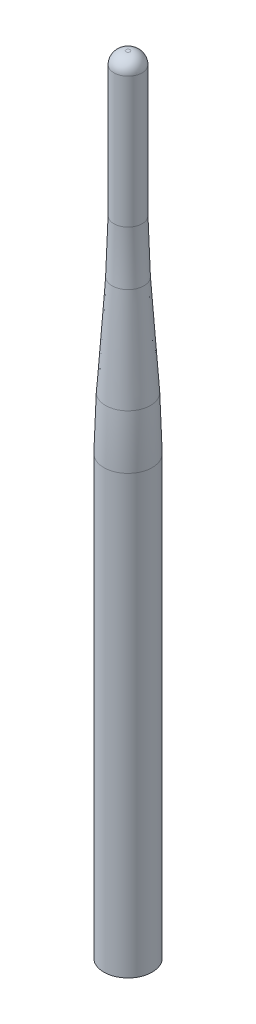
from build123d import *


with BuildPart() as part:
    # Sketch1 → Revolve1 (revolve)
    with BuildSketch(Plane.XY):
        with BuildLine():
            Line((0, 0), (0, 195))
            Line((0, 195), (-0.5, 195))
            ThreePointArc((-0.5, 195), (-2.621320344, 194.121320344), (-3.5, 192))
            Line((-3.5, 192), (-3.5, 159.571843893))
            ThreePointArc((-3.5, 159.571843893), (-3.607885473, 153.003545032), (-3.931425499, 146.442332412))
            Line((-3.931425499, 146.442332412), (-5.568574501, 121.557667588))
            ThreePointArc((-5.568574501, 121.557667588), (-5.892114527, 114.996454968), (-6, 108.428156107))
            Line((-6, 108.428156107), (-6, 0))
            Line((-6, 0), (0, 0))
        make_face()
    revolve(axis=Axis((0, 0, 0), (0, 1, 0)))


solid = part.part
